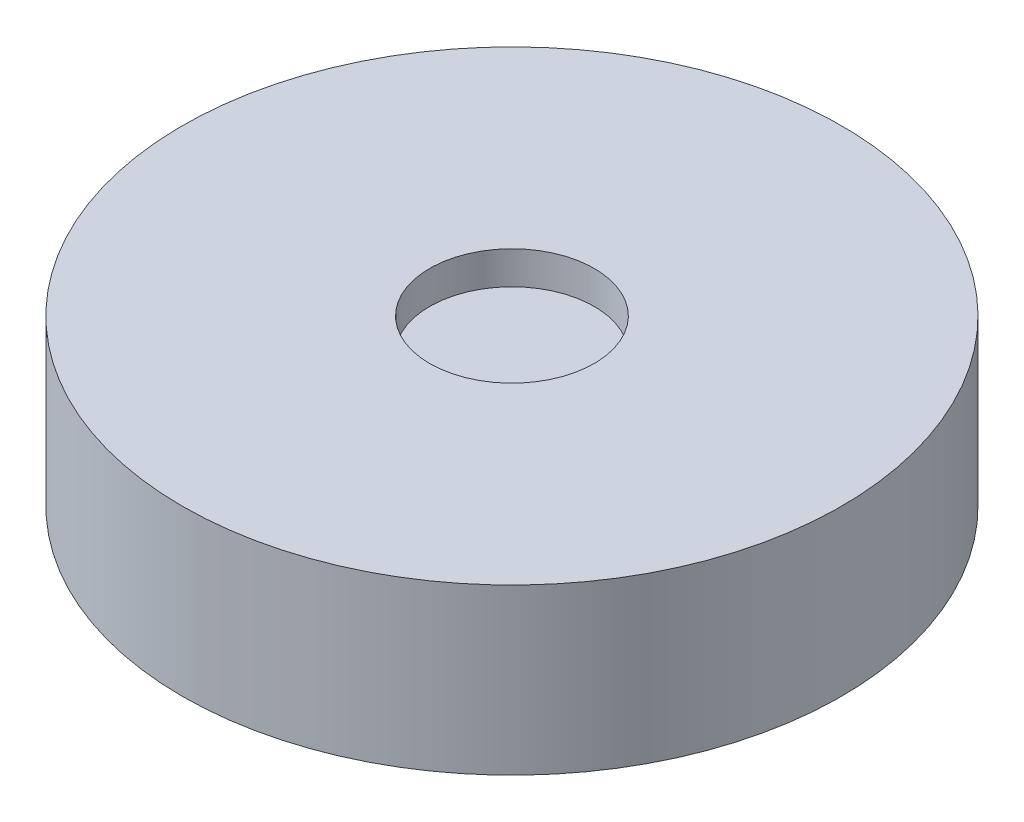
from build123d import *

# Parameters (mm, degrees)
SKETCH1_R           = 50.831653502
BOSS_EXTRUDE1_DEPTH = 25.4
SKETCH2_R           = 12.7
CUT_EXTRUDE1_DEPTH  = 5.08


with BuildPart() as part:
    # Sketch1 → Boss-Extrude1 (new body)
    with BuildSketch(Plane(origin=(0, 0, 0), x_dir=(1, 0, 0), z_dir=(0, 1, 0))):
        Circle(SKETCH1_R)
    extrude(amount=BOSS_EXTRUDE1_DEPTH)

    # Sketch2 → Cut-Extrude1 (cut)
    with BuildSketch(Plane(origin=(0, 25.4, 0), x_dir=(1, 0, 0), z_dir=(0, 1, 0))):
        Circle(SKETCH2_R)
    extrude(amount=-CUT_EXTRUDE1_DEPTH, mode=Mode.SUBTRACT)


solid = part.part
